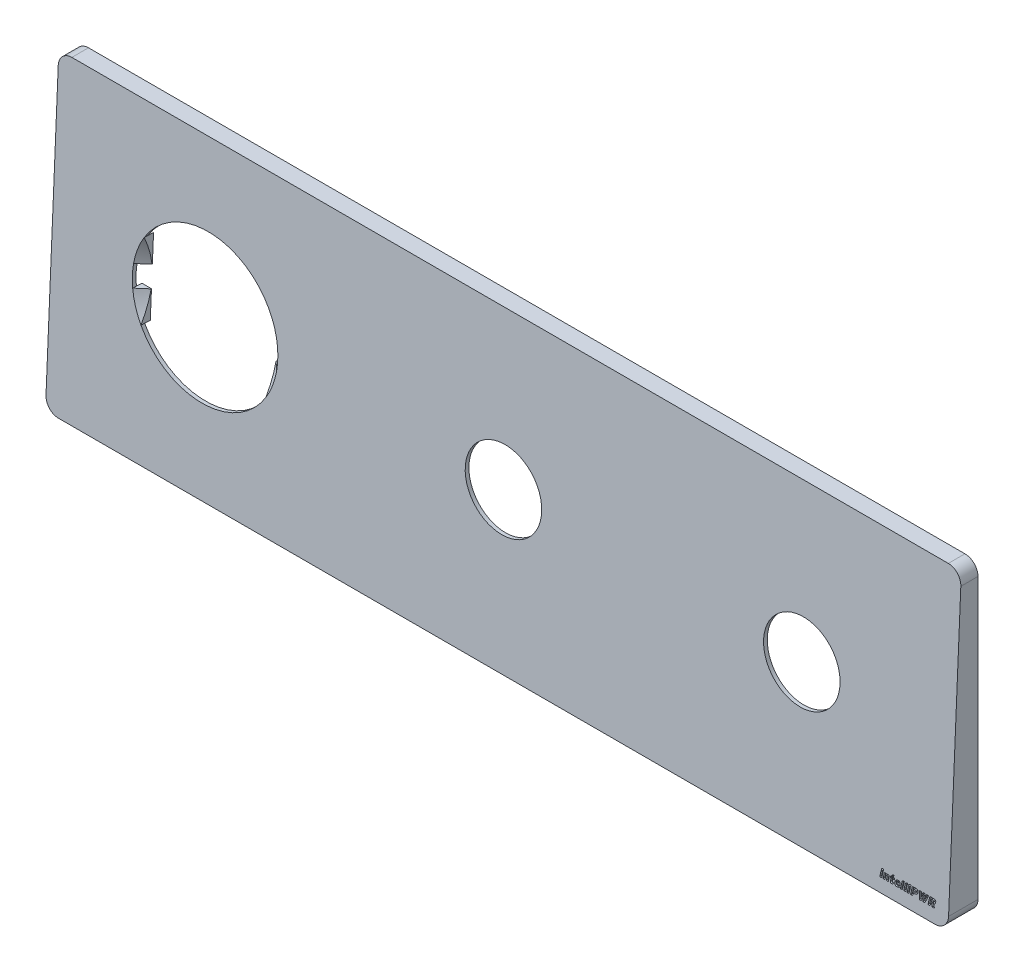
from build123d import *

# Parameters (mm, degrees)
EXTRUDE_THIN1_DEPTH         = 8
CUT_EXTRUDE2_DEPTH          = 242
BOSS_EXTRUDE1_DEPTH         = 242
KES_EKSTR_ZYON5_DEPTH       = 10
SKETCH8_R                   = 19.5
CUT_EXTRUDE3_DEPTH          = 82
CUT_EXTRUDE13_DEPTH         = 0.5
Y_KSEKLIK_EKSTR_ZYON1_DEPTH = 2.5
Y_KSEKLIK_EKSTR_ZYON4_REACH = 10.045
IZIM7_R                     = 5
KES_EKSTR_ZYON2_DEPTH       = 3
IZIM18_W                    = 228
IZIM18_H                    = 68
KES_EKSTR_ZYON8_DEPTH       = 1.5
IZIM19_R                    = 1.55
KES_EKSTR_ZYON10_DEPTH      = 2
IZIM20_R                    = 10.25
KES_EKSTR_ZYON11_DEPTH      = 2


with BuildPart() as part:
    # Sketch1 → Extrude-Thin1 (new body)
    with BuildSketch(Plane.XY):
        with BuildLine():
            Line((-37.5, 41), (197.5, 41))
            ThreePointArc((197.5, 41), (199.974873734, 39.974873734), (201, 37.5))
            Line((201, 37.5), (201, -37.5))
            ThreePointArc((201, -37.5), (199.974873734, -39.974873734), (197.5, -41))
            Line((197.5, -41), (-37.5, -41))
            ThreePointArc((-37.5, -41), (-39.974873734, -39.974873734), (-41, -37.5))
            Line((-41, -37.5), (-41, 37.5))
            ThreePointArc((-41, 37.5), (-39.974873734, 39.974873734), (-37.5, 41))
        make_face()
        with BuildLine():
            Line((-37.5, 40), (197.5, 40))
            ThreePointArc((197.5, 40), (199.267766953, 39.267766953), (200, 37.5))
            Line((200, 37.5), (200, -37.5))
            ThreePointArc((200, -37.5), (199.267766953, -39.267766953), (197.5, -40))
            Line((197.5, -40), (-37.5, -40))
            ThreePointArc((-37.5, -40), (-39.267766953, -39.267766953), (-40, -37.5))
            Line((-40, -37.5), (-40, 37.5))
            ThreePointArc((-40, 37.5), (-39.267766953, 39.267766953), (-37.5, 40))
        make_face(mode=Mode.SUBTRACT)
    extrude(amount=EXTRUDE_THIN1_DEPTH)

    # Sketch5 → Cut-Extrude2 (cut)
    with BuildSketch(Plane(origin=(201, 0, 0), x_dir=(0, 0, -1), z_dir=(1, 0, 0))):
        Polygon((-3.45625, 41), (-8, 41), (-8, -41), (-7.04375, -41), align=None)
    extrude(amount=-CUT_EXTRUDE2_DEPTH, mode=Mode.SUBTRACT)

    # Sketch6 → Boss-Extrude1 (add)
    with BuildSketch(Plane(origin=(201, 0, 0), x_dir=(0, 0, -1), z_dir=(1, 0, 0))):
        Polygon((-7.04375, -41), (-3.45625, 41), (-4.457206574, 41), (-8.044706574, -41), align=None)
    extrude(amount=-BOSS_EXTRUDE1_DEPTH)

    # Sketch7 → Kes-Ekstrüzyon5 (cut)
    with BuildSketch(Plane(origin=(0, 0, 0), x_dir=(-1, 0, 0), z_dir=(0, 0, -1))):
        with BuildLine():
            Line((-201, 37.5), (-201, 41))
            Line((-201, 41), (-197.5, 41))
            ThreePointArc((-197.5, 41), (-199.974873734, 39.974873734), (-201, 37.5))
        make_face()
        with BuildLine():
            Line((41, 41), (37.5, 41))
            ThreePointArc((37.5, 41), (39.974873734, 39.974873734), (41, 37.5))
            Line((41, 37.5), (41, 41))
        make_face()
        with BuildLine():
            Line((41, -37.5), (41, -41))
            Line((41, -41), (37.5, -41))
            ThreePointArc((37.5, -41), (39.974873734, -39.974873734), (41, -37.5))
        make_face()
        with BuildLine():
            Line((-201, -41), (-197.5, -41))
            ThreePointArc((-197.5, -41), (-199.974873734, -39.974873734), (-201, -37.5))
            Line((-201, -37.5), (-201, -41))
        make_face()
    extrude(amount=-KES_EKSTR_ZYON5_DEPTH, mode=Mode.SUBTRACT)

    # Sketch8 → Cut-Extrude3 (cut)
    with BuildSketch(Plane(origin=(0, 0.272956894, 6.23901471), x_dir=(1, 0, 0), z_dir=(0, 0.04370819, 0.99904434))):
        Circle(SKETCH8_R)
    extrude(amount=-CUT_EXTRUDE3_DEPTH, mode=Mode.SUBTRACT)

    # Sketch9 → Cut-Extrude13 (cut)
    with BuildSketch(Plane(origin=(0, 0.272956894, 6.23901471), x_dir=(1, 0, 0), z_dir=(0, 0.04370819, 0.99904434))):
        Polygon((182.531822821, -37.81243752), (182.856252467, -36.277424239), (183.382446053, -36.277424239), (183.058016406, -37.81243752), align=None)
        with BuildLine():
            Line((184.290595271, -37.81243752), (184.474593832, -36.930090398))
            add(Edge.make_bspline(
                [(184.474593832, -36.930090398), (184.478802242, -36.907040936), (184.485699122, -36.874149701), (184.489204408, -36.831864189), (184.489786804, -36.805005948), (184.488227016, -36.781187681), (184.484505468, -36.760299642), (184.478846794, -36.742301837), (184.467897911, -36.722954035), (184.449713773, -36.703469949), (184.410825862, -36.680379912), (184.375667943, -36.67553935), (184.351928125, -36.675453309)],
                knots=[0, 0, 0, 0, 0.206248224, 0.294567954, 0.37266766, 0.442257727, 0.504010297, 0.558886264, 0.607164005, 0.698384721, 0.78958017, 1, 1, 1, 1], degree=3))
            add(Edge.make_bspline(
                [(184.351928125, -36.675453309), (184.325473284, -36.67484558), (184.286525614, -36.681302878), (184.239553647, -36.702765608), (184.213865624, -36.721381884), (184.194964801, -36.739763636), (184.182562108, -36.757605017), (184.170154917, -36.777822133), (184.158964314, -36.801354271), (184.147757062, -36.827440773), (184.134571616, -36.86862437), (184.125790697, -36.901180323), (184.120978207, -36.924168606)],
                knots=[0, 0, 0, 0, 0.211446307, 0.310998659, 0.41131055, 0.464021143, 0.521401463, 0.584741643, 0.653943237, 0.72987757, 0.812025534, 1, 1, 1, 1], degree=3))
            Line((184.120978207, -36.924168606), (183.936556661, -37.81243752))
            Line((183.936556661, -37.81243752), (183.410363076, -37.81243752))
            Line((183.410363076, -37.81243752), (183.734792722, -36.26938752))
            Line((183.734792722, -36.26938752), (184.260986308, -36.26938752))
            Line((184.260986308, -36.26938752), (184.240683018, -36.373441879))
            add(Edge.make_bspline(
                [(184.240683018, -36.373441879), (184.297987543, -36.33807022), (184.373085655, -36.296555731), (184.471607475, -36.262409613), (184.549233248, -36.246533575), (184.610636762, -36.242418025), (184.653093586, -36.242316467)],
                knots=[0, 0, 0, 0, 0.46054381, 0.581347921, 0.710250487, 1, 1, 1, 1], degree=3))
            add(Edge.make_bspline(
                [(184.653093586, -36.242316467), (184.692136802, -36.242431818), (184.748815156, -36.246238609), (184.8195399, -36.26391656), (184.865428391, -36.281339933), (184.906090192, -36.304634337), (184.94136314, -36.333047361), (184.971485528, -36.366619173), (184.996169238, -36.405109022), (185.015420474, -36.448469614), (185.030965908, -36.495857326), (185.040105685, -36.548112348), (185.04586972, -36.604390706), (185.045678226, -36.66521683), (185.04090151, -36.755484326), (185.027642856, -36.824675469), (185.018552796, -36.872141426)],
                knots=[0, 0, 0, 0, 0.133987507, 0.193275728, 0.24925757, 0.301629359, 0.35316106, 0.403792674, 0.455518759, 0.509134706, 0.565968881, 0.625945932, 0.6905051, 0.759590801, 0.83411591, 1, 1, 1, 1], degree=3))
            Line((185.018552796, -36.872141426), (184.819749753, -37.81243752))
            Line((184.819749753, -37.81243752), (184.290595271, -37.81243752))
        make_face()
        with BuildLine():
            Line((185.394586637, -37.347153803), (185.534594737, -36.675453309))
            Line((185.534594737, -36.675453309), (185.300683923, -36.675453309))
            Line((185.300683923, -36.675453309), (185.388664844, -36.26938752))
            Line((185.388664844, -36.26938752), (185.622575658, -36.26938752))
            Line((185.622575658, -36.26938752), (185.704211801, -35.881087109))
            Line((185.704211801, -35.881087109), (186.259591365, -35.673824362))
            Line((186.259591365, -35.673824362), (186.133964762, -36.26938752))
            Line((186.133964762, -36.26938752), (186.467277097, -36.26938752))
            Line((186.467277097, -36.26938752), (186.379719161, -36.675453309))
            Line((186.379719161, -36.675453309), (186.046406826, -36.675453309))
            Line((186.046406826, -36.675453309), (185.929239926, -37.238869592))
            add(Edge.make_bspline(
                [(185.929239926, -37.238869592), (185.923631424, -37.263216042), (185.918218034, -37.297200918), (185.92312076, -37.33870405), (185.933824276, -37.360093), (185.95091673, -37.374576816), (185.981808804, -37.389433205), (186.009637148, -37.390972473), (186.028641447, -37.391567249)],
                knots=[0, 0, 0, 0, 0.332431059, 0.451864296, 0.549008946, 0.641835514, 0.743993136, 1, 1, 1, 1], degree=3))
            add(Edge.make_bspline(
                [(186.028641447, -37.391567249), (186.064780722, -37.392002115), (186.110181113, -37.38175387), (186.162442535, -37.359627978), (186.203981464, -37.340089416), (186.235299865, -37.32233029), (186.257053454, -37.309931106)],
                knots=[0, 0, 0, 0, 0.43902333, 0.560347006, 0.693743593, 1, 1, 1, 1], degree=3))
            Line((186.257053454, -37.309931106), (186.092935197, -37.757449444))
            add(Edge.make_bspline(
                [(186.092935197, -37.757449444), (186.033275974, -37.783688944), (185.9542673, -37.808911724), (185.856030319, -37.827809595), (185.785408909, -37.836780083), (185.731643106, -37.839786288), (185.695329112, -37.839508573)],
                knots=[0, 0, 0, 0, 0.477930884, 0.605353718, 0.733676339, 1, 1, 1, 1], degree=3))
            add(Edge.make_bspline(
                [(185.695329112, -37.839508573), (185.663071209, -37.839736582), (185.616436461, -37.836590683), (185.557875684, -37.82439235), (185.519836592, -37.812291359), (185.486172578, -37.796278005), (185.456955472, -37.776434565), (185.431516542, -37.753616181), (185.410851111, -37.726296633), (185.394665646, -37.694759799), (185.38251301, -37.658826153), (185.374110771, -37.618366346), (185.370071442, -37.573117994), (185.370413325, -37.523190221), (185.37572401, -37.446876072), (185.386376133, -37.387870854), (185.394586637, -37.347153803)],
                knots=[0, 0, 0, 0, 0.137072389, 0.197691701, 0.253760369, 0.306270191, 0.355445666, 0.403353528, 0.450794793, 0.500090506, 0.553319674, 0.611470956, 0.675245672, 0.745926336, 0.823383702, 1, 1, 1, 1], degree=3))
        make_face()
        with BuildLine():
            Line((187.91938528, -37.189803309), (187.01927278, -37.189803309))
            add(Edge.make_bspline(
                [(187.01927278, -37.189803309), (187.015898274, -37.226457242), (187.01601409, -37.279183424), (187.03669972, -37.341985199), (187.061308535, -37.376691917), (187.093763275, -37.402446593), (187.147771512, -37.428419222), (187.19477816, -37.432833272), (187.226535526, -37.433442783)],
                knots=[0, 0, 0, 0, 0.296055755, 0.414655706, 0.524028038, 0.631630635, 0.743271398, 1, 1, 1, 1], degree=3))
            add(Edge.make_bspline(
                [(187.226535526, -37.433442783), (187.260304962, -37.433236623), (187.31067195, -37.43030854), (187.376808197, -37.419896308), (187.426276206, -37.409482171), (187.476966935, -37.393776547), (187.552204889, -37.368515828), (187.608599837, -37.34239729), (187.647828783, -37.325158573)],
                knots=[0, 0, 0, 0, 0.230947891, 0.344109465, 0.457558095, 0.576207715, 0.70668566, 1, 1, 1, 1], degree=3))
            Line((187.647828783, -37.325158573), (187.779377179, -37.663123745))
            add(Edge.make_bspline(
                [(187.779377179, -37.663123745), (187.727053342, -37.69106355), (187.647293355, -37.728389628), (187.538548692, -37.768901332), (187.457845603, -37.794776995), (187.375596177, -37.814738758), (187.261882842, -37.834279371), (187.174496056, -37.839220378), (187.115713405, -37.839508573)],
                knots=[0, 0, 0, 0, 0.256454148, 0.380104154, 0.501569382, 0.622663836, 0.745735429, 1, 1, 1, 1], degree=3))
            add(Edge.make_bspline(
                [(187.115713405, -37.839508573), (187.062179079, -37.839286621), (186.984150161, -37.83327018), (186.88635986, -37.808329984), (186.821962158, -37.782879161), (186.764092487, -37.750669591), (186.712897628, -37.712208672), (186.667893943, -37.668395916), (186.62986787, -37.618343197), (186.599121942, -37.56243437), (186.574364264, -37.501573328), (186.556779358, -37.435320793), (186.545435886, -37.364186815), (186.541005333, -37.288550103), (186.544084404, -37.180061075), (186.556760714, -37.097618609), (186.568793544, -37.042181476)],
                knots=[0, 0, 0, 0, 0.139838784, 0.202933442, 0.262718436, 0.320042211, 0.375233846, 0.429352927, 0.483441981, 0.53862135, 0.595400523, 0.654488518, 0.717096367, 0.783082629, 0.851912792, 1, 1, 1, 1], degree=3))
            add(Edge.make_bspline(
                [(186.568793544, -37.042181476), (186.583085354, -36.979206373), (186.60848624, -36.887640456), (186.655114524, -36.772897044), (186.694694701, -36.695308707), (186.738238344, -36.623502999), (186.786046479, -36.557832048), (186.837870332, -36.498114858), (186.893872235, -36.444840081), (186.953078454, -36.39729059), (187.015434303, -36.35616866), (187.080683136, -36.32115439), (187.14867641, -36.29247145), (187.219054765, -36.270059906), (187.315753588, -36.248224211), (187.39033929, -36.242847847), (187.440143051, -36.242316467)],
                knots=[0, 0, 0, 0, 0.150666393, 0.221012111, 0.28851275, 0.353592776, 0.416668091, 0.477731317, 0.537737092, 0.596692125, 0.65460536, 0.711686431, 0.769156404, 0.826456793, 0.883737364, 1, 1, 1, 1], degree=3))
            add(Edge.make_bspline(
                [(187.440143051, -36.242316467), (187.48922651, -36.24267976), (187.561151065, -36.24758194), (187.651468494, -36.270502973), (187.711979381, -36.293016875), (187.766658046, -36.323010534), (187.815967781, -36.359353432), (187.859729134, -36.4023055), (187.897814959, -36.451871329), (187.929209579, -36.508297206), (187.953961332, -36.571393781), (187.97038317, -36.641490792), (187.980634306, -36.717983158), (187.982669075, -36.801137222), (187.975856843, -36.92586239), (187.959950401, -37.021979864), (187.946033347, -37.087863877)],
                knots=[0, 0, 0, 0, 0.12523536, 0.182281535, 0.236835406, 0.289223704, 0.340575345, 0.392377008, 0.444879637, 0.499220359, 0.55630156, 0.616919283, 0.68212815, 0.752543466, 0.82841511, 1, 1, 1, 1], degree=3))
            add(Edge.make_bspline(
                [(187.946033347, -37.087863877), (187.940848511, -37.106752883), (187.933318431, -37.141050311), (187.92588395, -37.175490124), (187.91938528, -37.189803309)],
                knots=[0, 0, 0, 0, 0.556454368, 1, 1, 1, 1], degree=3))
        make_face()
        with BuildLine():
            Line((187.089065337, -36.864950678), (187.527700987, -36.864950678))
            add(Edge.make_bspline(
                [(187.527700987, -36.864950678), (187.529337401, -36.829487736), (187.529026457, -36.77893147), (187.514215784, -36.717849161), (187.500871129, -36.6876486), (187.487156087, -36.667260541), (187.473605439, -36.655183968), (187.4583103, -36.644290122), (187.440041106, -36.635904218), (187.419470388, -36.629193279), (187.387146007, -36.622924997), (187.361546751, -36.621026515), (187.343702426, -36.621311204)],
                knots=[0, 0, 0, 0, 0.296748963, 0.41669466, 0.52130206, 0.570189777, 0.620055625, 0.671541666, 0.72618717, 0.786738208, 0.851474558, 1, 1, 1, 1], degree=3))
            add(Edge.make_bspline(
                [(187.343702426, -36.621311204), (187.315511409, -36.621200824), (187.27322467, -36.62837339), (187.223193569, -36.654754005), (187.18938015, -36.682031228), (187.158746996, -36.716815862), (187.120773112, -36.776433731), (187.10084266, -36.828342644), (187.089065337, -36.864950678)],
                knots=[0, 0, 0, 0, 0.222963425, 0.331063086, 0.443598367, 0.564296996, 0.69558842, 1, 1, 1, 1], degree=3))
        make_face(mode=Mode.SUBTRACT)
        Polygon((188.08138861, -37.81243752), (188.4874544, -35.884893976), (189.057638446, -35.673824362), (188.607582196, -37.81243752), align=None)
        Polygon((188.974733347, -37.81243752), (189.380799137, -35.884893976), (189.950983183, -35.673824362), (189.500926933, -37.81243752), align=None)
        Polygon((189.868078084, -37.81243752), (190.19250773, -36.277424239), (190.718701316, -36.277424239), (190.394271669, -37.81243752), align=None)
        with BuildLine():
            Line((191.772780428, -37.135661204), (191.489380345, -37.135661204))
            Line((191.489380345, -37.135661204), (191.34894926, -37.81243752))
            Line((191.34894926, -37.81243752), (190.790608799, -37.81243752))
            Line((190.790608799, -37.81243752), (191.223322656, -35.75503752))
            Line((191.223322656, -35.75503752), (192.103131867, -35.75503752))
            add(Edge.make_bspline(
                [(192.103131867, -35.75503752), (192.159534536, -35.754461725), (192.241971066, -35.759373362), (192.34812403, -35.774557347), (192.42051447, -35.790648003), (192.487750703, -35.810772195), (192.548378699, -35.837608583), (192.602942888, -35.869231698), (192.650276048, -35.907283046), (192.691096218, -35.950762718), (192.72462258, -36.000691089), (192.750395085, -36.056994678), (192.768534882, -36.119550733), (192.779127087, -36.188477535), (192.781433901, -36.294101393), (192.769834596, -36.376142847), (192.758335937, -36.432236821)],
                knots=[0, 0, 0, 0, 0.14831325, 0.216934671, 0.281917028, 0.343283354, 0.401251238, 0.455965678, 0.508744428, 0.560452414, 0.612307896, 0.666251039, 0.722712036, 0.783153078, 0.849210812, 1, 1, 1, 1], degree=3))
            add(Edge.make_bspline(
                [(192.758335937, -36.432236821), (192.745018379, -36.493400096), (192.720669996, -36.582253241), (192.670543899, -36.690589416), (192.628175407, -36.76221581), (192.579864514, -36.826142449), (192.527763822, -36.884522206), (192.469918315, -36.935510004), (192.407912463, -36.980860955), (192.341061715, -37.019087162), (192.270613234, -37.052413334), (192.195941581, -37.079438209), (192.117438362, -37.100302612), (192.035627861, -37.116510214), (191.920519083, -37.130666622), (191.832448592, -37.136469779), (191.772780428, -37.135661204)],
                knots=[0, 0, 0, 0, 0.14135813, 0.206506788, 0.268663819, 0.328624165, 0.386922124, 0.444795496, 0.502155746, 0.559848074, 0.618159034, 0.677698161, 0.738624222, 0.801161417, 0.865596376, 1, 1, 1, 1], degree=3))
        make_face()
        with BuildLine():
            Line((191.992309745, -36.215245415), (191.685222492, -36.215245415))
            Line((191.685222492, -36.215245415), (191.58582097, -36.675453309))
            Line((191.58582097, -36.675453309), (191.884025535, -36.675453309))
            add(Edge.make_bspline(
                [(191.884025535, -36.675453309), (191.925283313, -36.675209328), (191.984662794, -36.670227561), (192.055154824, -36.644667406), (192.096879938, -36.618845247), (192.130162263, -36.584340573), (192.167941671, -36.52744984), (192.183954356, -36.476480956), (192.191112788, -36.44111951)],
                knots=[0, 0, 0, 0, 0.290619666, 0.412091533, 0.523258856, 0.631698278, 0.745850168, 1, 1, 1, 1], degree=3))
            add(Edge.make_bspline(
                [(192.191112788, -36.44111951), (192.198110418, -36.410987258), (192.203090618, -36.36614806), (192.190734347, -36.310322247), (192.175987355, -36.281723428), (192.160016208, -36.261866207), (192.144631485, -36.249338003), (192.126367347, -36.238587545), (192.105357328, -36.229711955), (192.081040299, -36.223694155), (192.043444894, -36.216386171), (192.013189918, -36.215204357), (191.992309745, -36.215245415)],
                knots=[0, 0, 0, 0, 0.254137898, 0.360692933, 0.46331412, 0.514097368, 0.56812747, 0.624481852, 0.687008785, 0.753851467, 0.828927712, 1, 1, 1, 1], degree=3))
        make_face(mode=Mode.SUBTRACT)
        with BuildLine():
            Line((194.659231414, -37.81243752), (194.129230962, -37.81243752))
            Line((194.129230962, -37.81243752), (194.129230962, -37.365765152))
            add(Edge.make_bspline(
                [(194.129230962, -37.365765152), (194.126900951, -37.283994804), (194.128252893, -37.160536588), (194.13547643, -36.997616177), (194.140789961, -36.879311843), (194.146666584, -36.769053746), (194.151864415, -36.683348569), (194.155460175, -36.621114495), (194.160496198, -36.570625063), (194.164210151, -36.535200839), (194.167722615, -36.513449979)],
                knots=[0, 0, 0, 0, 0.287418182, 0.433706581, 0.573086252, 0.703582808, 0.821711634, 0.874841658, 0.922616611, 1, 1, 1, 1], degree=3))
            add(Edge.make_bspline(
                [(194.167722615, -36.513449979), (194.161496588, -36.535520096), (194.149299246, -36.570573469), (194.134017602, -36.621303223), (194.118978254, -36.666114788), (194.103325378, -36.714945055), (194.085340593, -36.766621059), (194.066093035, -36.820983598), (194.03725522, -36.897664284), (193.9987844, -36.997892012), (193.933873577, -37.161042447), (193.883548654, -37.284308092), (193.849214762, -37.365765152)],
                knots=[0, 0, 0, 0, 0.075537836, 0.122272145, 0.174582572, 0.231301047, 0.291254257, 0.354891756, 0.421348915, 0.56122885, 0.708689565, 1, 1, 1, 1], degree=3))
            Line((193.849214762, -37.365765152), (193.661832319, -37.81243752))
            Line((193.661832319, -37.81243752), (193.144521423, -37.81243752))
            Line((193.144521423, -37.81243752), (193.089110362, -35.75503752))
            Line((193.089110362, -35.75503752), (193.673675905, -35.75503752))
            Line((193.673675905, -35.75503752), (193.656333512, -36.098924485))
            add(Edge.make_bspline(
                [(193.656333512, -36.098924485), (193.65424701, -36.174983918), (193.648264891, -36.290478133), (193.63833161, -36.445240669), (193.629727747, -36.562669926), (193.621321528, -36.67807013), (193.607761646, -36.820968946), (193.598473633, -36.925344182), (193.591616776, -36.992269222)],
                knots=[0, 0, 0, 0, 0.254778508, 0.38725736, 0.519329184, 0.649081567, 0.774717154, 1, 1, 1, 1], degree=3))
            add(Edge.make_bspline(
                [(193.591616776, -36.992269222), (193.61165122, -36.925090754), (193.64627647, -36.821122294), (193.699313362, -36.68033524), (193.744037038, -36.566523172), (193.79127081, -36.450651757), (193.852019877, -36.294789455), (193.898907874, -36.178549694), (193.930850905, -36.101885382)],
                knots=[0, 0, 0, 0, 0.220629604, 0.344767136, 0.47349051, 0.605507784, 0.738597758, 1, 1, 1, 1], degree=3))
            Line((193.930850905, -36.101885382), (194.074242887, -35.75503752))
            Line((194.074242887, -35.75503752), (194.600436472, -35.75503752))
            Line((194.600436472, -35.75503752), (194.597475576, -36.101885382))
            add(Edge.make_bspline(
                [(194.597475576, -36.101885382), (194.595245322, -36.17885342), (194.593744967, -36.295183632), (194.59170112, -36.450432417), (194.58933481, -36.566770504), (194.585265185, -36.680726113), (194.576970765, -36.822355136), (194.568781216, -36.925808509), (194.562367804, -36.992269222)],
                knots=[0, 0, 0, 0, 0.259139328, 0.391547022, 0.522548461, 0.650759617, 0.775290273, 1, 1, 1, 1], degree=3))
            add(Edge.make_bspline(
                [(194.562367804, -36.992269222), (194.582394712, -36.924994766), (194.615222507, -36.82040396), (194.663469422, -36.677898334), (194.702776993, -36.562353946), (194.74497043, -36.44495472), (194.802596037, -36.290539958), (194.846106719, -36.175456577), (194.872415954, -36.098924485)],
                knots=[0, 0, 0, 0, 0.222643769, 0.347663635, 0.477213716, 0.609762054, 0.743343773, 1, 1, 1, 1], degree=3))
            Line((194.872415954, -36.098924485), (195.001003454, -35.75503752))
            Line((195.001003454, -35.75503752), (195.580070189, -35.75503752))
            Line((195.580070189, -35.75503752), (194.659231414, -37.81243752))
        make_face()
        with BuildLine():
            Line((196.593542722, -37.81243752), (196.406583265, -37.135661204))
            Line((196.406583265, -37.135661204), (196.178594243, -37.135661204))
            Line((196.178594243, -37.135661204), (196.032241365, -37.81243752))
            Line((196.032241365, -37.81243752), (195.473900905, -37.81243752))
            Line((195.473900905, -37.81243752), (195.906614762, -35.75503752))
            Line((195.906614762, -35.75503752), (196.821531743, -35.75503752))
            add(Edge.make_bspline(
                [(196.821531743, -35.75503752), (196.877926873, -35.754483807), (196.960384904, -35.759332471), (197.066505033, -35.774612626), (197.139020737, -35.790466145), (197.205953379, -35.811436437), (197.266900634, -35.837465743), (197.321219528, -35.86927989), (197.368651198, -35.906963709), (197.409975253, -35.949728838), (197.443119472, -35.999356773), (197.469792369, -36.054460359), (197.488179297, -36.116142105), (197.499234619, -36.184069182), (197.502091304, -36.288441986), (197.491138593, -36.369579554), (197.479273725, -36.425046073)],
                knots=[0, 0, 0, 0, 0.149105791, 0.218093904, 0.283423508, 0.345229253, 0.403357541, 0.458364359, 0.511192647, 0.563160888, 0.614984401, 0.668362726, 0.724518171, 0.784604297, 0.849908347, 1, 1, 1, 1], degree=3))
            add(Edge.make_bspline(
                [(197.479273725, -36.425046073), (197.471091951, -36.462370246), (197.457436855, -36.517331944), (197.43109931, -36.586817422), (197.410288931, -36.63589911), (197.386568462, -36.682146783), (197.360046921, -36.725521274), (197.331535273, -36.766605713), (197.289678358, -36.81710195), (197.232396706, -36.874721204), (197.129930057, -36.955845139), (197.043268199, -37.00306597), (196.982266118, -37.027799979)],
                knots=[0, 0, 0, 0, 0.140674907, 0.207617019, 0.273117689, 0.336661801, 0.398557529, 0.459984484, 0.520402942, 0.639569431, 0.758047993, 1, 1, 1, 1], degree=3))
            Line((196.982266118, -37.027799979), (197.228020518, -37.81243752))
            Line((197.228020518, -37.81243752), (196.593542722, -37.81243752))
        make_face()
        with BuildLine():
            Line((196.710709622, -36.215245415), (196.368514597, -36.215245415))
            Line((196.368514597, -36.215245415), (196.272073972, -36.675453309))
            Line((196.272073972, -36.675453309), (196.605386308, -36.675453309))
            add(Edge.make_bspline(
                [(196.605386308, -36.675453309), (196.646692183, -36.675332321), (196.705978767, -36.670056218), (196.776403605, -36.643820336), (196.817731516, -36.616951584), (196.851342385, -36.58260588), (196.88863205, -36.525830349), (196.904630746, -36.475608567), (196.912050576, -36.440696525)],
                knots=[0, 0, 0, 0, 0.291424493, 0.412585485, 0.525065724, 0.635142904, 0.748168098, 1, 1, 1, 1], degree=3))
            add(Edge.make_bspline(
                [(196.912050576, -36.440696525), (196.917844475, -36.411390256), (196.922675548, -36.366980493), (196.90794214, -36.31244527), (196.893225565, -36.28331352), (196.876706606, -36.263321356), (196.861459444, -36.249962849), (196.842692221, -36.239762671), (196.822035314, -36.229989575), (196.797925906, -36.22366887), (196.760859123, -36.216450838), (196.731169116, -36.215191251), (196.710709622, -36.215245415)],
                knots=[0, 0, 0, 0, 0.248424975, 0.356513751, 0.46136469, 0.51411026, 0.569240084, 0.626959334, 0.689288847, 0.756873603, 0.831295405, 1, 1, 1, 1], degree=3))
        make_face(mode=Mode.SUBTRACT)
        with BuildLine():
            add(Edge.make_bspline(
                [(183.50511176, -35.900967413), (183.49691936, -35.939534043), (183.47504383, -35.995133722), (183.425881126, -36.056740916), (183.380038303, -36.094110103), (183.328076843, -36.124265142), (183.249409757, -36.153091049), (183.185884765, -36.161544068), (183.142613446, -36.161103309)],
                knots=[0, 0, 0, 0, 0.243996234, 0.362518467, 0.483923593, 0.607810429, 0.732572499, 1, 1, 1, 1], degree=3))
            add(Edge.make_bspline(
                [(183.142613446, -36.161103309), (183.103364668, -36.161400076), (183.046373744, -36.154280511), (182.979352972, -36.124674591), (182.945948828, -36.099189041), (182.924597095, -36.074893347), (182.910930194, -36.055259817), (182.901500015, -36.033273015), (182.894040832, -36.01010401), (182.890391407, -35.984987846), (182.889303064, -35.948291927), (182.893286288, -35.92001209), (182.897282031, -35.900967413)],
                knots=[0, 0, 0, 0, 0.278361244, 0.398908763, 0.514847654, 0.572097947, 0.627438768, 0.683254165, 0.740686715, 0.799243397, 0.862127538, 1, 1, 1, 1], degree=3))
            add(Edge.make_bspline(
                [(182.897282031, -35.900967413), (182.90463722, -35.864843953), (182.926908821, -35.812948349), (182.975049057, -35.754537867), (183.02082171, -35.717115039), (183.07287559, -35.686103781), (183.14944575, -35.654434845), (183.212194736, -35.647389995), (183.253858553, -35.646753309)],
                knots=[0, 0, 0, 0, 0.233168972, 0.351345779, 0.477078281, 0.606225183, 0.734604908, 1, 1, 1, 1], degree=3))
            add(Edge.make_bspline(
                [(183.253858553, -35.646753309), (183.294043937, -35.647611873), (183.353611721, -35.652601871), (183.421520668, -35.685173743), (183.454901582, -35.711763501), (183.475557012, -35.736857178), (183.489276756, -35.75628574), (183.498634374, -35.777727473), (183.506206896, -35.800008962), (183.51029148, -35.823685041), (183.51182755, -35.85767362), (183.50937443, -35.883664153), (183.50511176, -35.900967413)],
                knots=[0, 0, 0, 0, 0.289932119, 0.415109387, 0.533191086, 0.591068146, 0.646913169, 0.702320899, 0.757398382, 0.814668092, 0.873137526, 1, 1, 1, 1], degree=3))
        make_face()
        with BuildLine():
            add(Edge.make_bspline(
                [(190.841367023, -35.900967413), (190.833174623, -35.939534043), (190.811299094, -35.995133722), (190.762136389, -36.056740916), (190.716293567, -36.094110103), (190.664332107, -36.124265142), (190.58566502, -36.153091049), (190.522140028, -36.161544068), (190.478868709, -36.161103309)],
                knots=[0, 0, 0, 0, 0.243996234, 0.362518467, 0.483923593, 0.607810429, 0.732572499, 1, 1, 1, 1], degree=3))
            add(Edge.make_bspline(
                [(190.478868709, -36.161103309), (190.439619931, -36.161400076), (190.382629007, -36.154280511), (190.315608235, -36.124674591), (190.282204092, -36.099189041), (190.260852358, -36.074893347), (190.247185457, -36.055259817), (190.237755278, -36.033273015), (190.230296095, -36.01010401), (190.226646671, -35.984987846), (190.225558327, -35.948291927), (190.229541551, -35.92001209), (190.233537294, -35.900967413)],
                knots=[0, 0, 0, 0, 0.278361244, 0.398908763, 0.514847654, 0.572097947, 0.627438768, 0.683254165, 0.740686715, 0.799243397, 0.862127538, 1, 1, 1, 1], degree=3))
            add(Edge.make_bspline(
                [(190.233537294, -35.900967413), (190.240892483, -35.864843953), (190.263164084, -35.812948349), (190.31130432, -35.754537867), (190.357076973, -35.717115039), (190.409130853, -35.686103781), (190.485701013, -35.654434845), (190.54845, -35.647389995), (190.590113816, -35.646753309)],
                knots=[0, 0, 0, 0, 0.233168972, 0.351345779, 0.477078281, 0.606225183, 0.734604908, 1, 1, 1, 1], degree=3))
            add(Edge.make_bspline(
                [(190.590113816, -35.646753309), (190.6302992, -35.647611873), (190.689866985, -35.652601871), (190.757775931, -35.685173743), (190.791156845, -35.711763501), (190.811812275, -35.736857178), (190.825532019, -35.75628574), (190.834889637, -35.777727473), (190.842462159, -35.800008962), (190.846546743, -35.823685041), (190.848082813, -35.85767362), (190.845629693, -35.883664153), (190.841367023, -35.900967413)],
                knots=[0, 0, 0, 0, 0.289932119, 0.415109387, 0.533191086, 0.591068146, 0.646913169, 0.702320899, 0.757398382, 0.814668092, 0.873137526, 1, 1, 1, 1], degree=3))
        make_face()
    extrude(amount=-CUT_EXTRUDE13_DEPTH, mode=Mode.SUBTRACT)

    # Çizim2 → Yükseklik-Ekstrüzyon1 (add)
    with BuildSketch(Plane(origin=(0, 0.272956894, 6.23901471), x_dir=(1, 0, 0), z_dir=(0, 0.04370819, 0.99904434))):
        with BuildLine():
            Line((-16.75, 2.8), (-16.75, 9.984362774))
            ThreePointArc((-16.75, 9.984362774), (-18.37843937, 6.517895851), (-19.29792735, 2.8))
            Line((-19.29792735, 2.8), (-16.75, 2.8))
        make_face()
        with BuildLine():
            ThreePointArc((-19.29792735, -2.8), (-18.37843937, -6.517895851), (-16.75, -9.984362774))
            Line((-16.75, -9.984362774), (-16.75, -2.8))
            Line((-16.75, -2.8), (-19.29792735, -2.8))
        make_face()
        with BuildLine():
            Line((16.75, 2.8), (19.29792735, 2.8))
            ThreePointArc((19.29792735, 2.8), (18.37843937, 6.517895851), (16.75, 9.984362774))
            Line((16.75, 9.984362774), (16.75, 2.8))
        make_face()
        with BuildLine():
            ThreePointArc((16.75, -9.984362774), (18.37843937, -6.517895851), (19.29792735, -2.8))
            Line((19.29792735, -2.8), (16.75, -2.8))
            Line((16.75, -2.8), (16.75, -9.984362774))
        make_face()
    extrude(amount=-Y_KSEKLIK_EKSTR_ZYON1_DEPTH)

    # Çizim4 → Kes-Döndür2 (revolve, cut)
    with BuildSketch(Plane(origin=(0, 0, 0), x_dir=(-1, 0, 0), z_dir=(0, -0.99904434, 0.04370819))):
        Polygon((19.5, -6.244982787), (16.9, -3.744982787), (16.9, -6.244982787), align=None)
    revolve(axis=Axis((0, -1.000417569, -22.866687299), (0, 0.04370819, 0.99904434)), mode=Mode.SUBTRACT)

    # Çizim7 → Yükseklik-Ekstrüzyon4 (add, up to next)
    with BuildSketch(Plane(origin=(0, 0, 0), x_dir=(-1, 0, 0), z_dir=(0, 0, -1)), mode=Mode.PRIVATE) as y_kseklik_ekstr_zyon4_sk1:
        with Locations((29, -29)):
            Circle(IZIM7_R)
    y_kseklik_ekstr_zyon4_tool1 = extrude(y_kseklik_ekstr_zyon4_sk1.sketch, amount=-Y_KSEKLIK_EKSTR_ZYON4_REACH, mode=Mode.PRIVATE) - part.part
    add(y_kseklik_ekstr_zyon4_tool1.solids().sort_by_distance((-29, -29, 0))[0])
    # Çizim7 → Yükseklik-Ekstrüzyon4 (add, up to next)
    with BuildSketch(Plane(origin=(0, 0, 0), x_dir=(-1, 0, 0), z_dir=(0, 0, -1)), mode=Mode.PRIVATE) as y_kseklik_ekstr_zyon4_sk2:
        with Locations((29, 29)):
            Circle(IZIM7_R)
    y_kseklik_ekstr_zyon4_tool2 = extrude(y_kseklik_ekstr_zyon4_sk2.sketch, amount=-Y_KSEKLIK_EKSTR_ZYON4_REACH, mode=Mode.PRIVATE) - part.part
    add(y_kseklik_ekstr_zyon4_tool2.solids().sort_by_distance((-29, 29, 0))[0])
    # Çizim7 → Yükseklik-Ekstrüzyon4 (add, up to next)
    with BuildSketch(Plane(origin=(0, 0, 0), x_dir=(-1, 0, 0), z_dir=(0, 0, -1)), mode=Mode.PRIVATE) as y_kseklik_ekstr_zyon4_sk3:
        with Locations((-29, -29)):
            Circle(IZIM7_R)
    y_kseklik_ekstr_zyon4_tool3 = extrude(y_kseklik_ekstr_zyon4_sk3.sketch, amount=-Y_KSEKLIK_EKSTR_ZYON4_REACH, mode=Mode.PRIVATE) - part.part
    add(y_kseklik_ekstr_zyon4_tool3.solids().sort_by_distance((29, -29, 0))[0])
    # Çizim7 → Yükseklik-Ekstrüzyon4 (add, up to next)
    with BuildSketch(Plane(origin=(0, 0, 0), x_dir=(-1, 0, 0), z_dir=(0, 0, -1)), mode=Mode.PRIVATE) as y_kseklik_ekstr_zyon4_sk4:
        with Locations((-29, 29)):
            Circle(IZIM7_R)
    y_kseklik_ekstr_zyon4_tool4 = extrude(y_kseklik_ekstr_zyon4_sk4.sketch, amount=-Y_KSEKLIK_EKSTR_ZYON4_REACH, mode=Mode.PRIVATE) - part.part
    add(y_kseklik_ekstr_zyon4_tool4.solids().sort_by_distance((29, 29, 0))[0])
    # Çizim7 → Yükseklik-Ekstrüzyon4 (add, up to next)
    with BuildSketch(Plane(origin=(0, 0, 0), x_dir=(-1, 0, 0), z_dir=(0, 0, -1)), mode=Mode.PRIVATE) as y_kseklik_ekstr_zyon4_sk5:
        with Locations((-51, -29)):
            Circle(IZIM7_R)
    y_kseklik_ekstr_zyon4_tool5 = extrude(y_kseklik_ekstr_zyon4_sk5.sketch, amount=-Y_KSEKLIK_EKSTR_ZYON4_REACH, mode=Mode.PRIVATE) - part.part
    add(y_kseklik_ekstr_zyon4_tool5.solids().sort_by_distance((51, -29, 0))[0])
    # Çizim7 → Yükseklik-Ekstrüzyon4 (add, up to next)
    with BuildSketch(Plane(origin=(0, 0, 0), x_dir=(-1, 0, 0), z_dir=(0, 0, -1)), mode=Mode.PRIVATE) as y_kseklik_ekstr_zyon4_sk6:
        with Locations((-109, -29)):
            Circle(IZIM7_R)
    y_kseklik_ekstr_zyon4_tool6 = extrude(y_kseklik_ekstr_zyon4_sk6.sketch, amount=-Y_KSEKLIK_EKSTR_ZYON4_REACH, mode=Mode.PRIVATE) - part.part
    add(y_kseklik_ekstr_zyon4_tool6.solids().sort_by_distance((109, -29, 0))[0])
    # Çizim7 → Yükseklik-Ekstrüzyon4 (add, up to next)
    with BuildSketch(Plane(origin=(0, 0, 0), x_dir=(-1, 0, 0), z_dir=(0, 0, -1)), mode=Mode.PRIVATE) as y_kseklik_ekstr_zyon4_sk7:
        with Locations((-131, -29)):
            Circle(IZIM7_R)
    y_kseklik_ekstr_zyon4_tool7 = extrude(y_kseklik_ekstr_zyon4_sk7.sketch, amount=-Y_KSEKLIK_EKSTR_ZYON4_REACH, mode=Mode.PRIVATE) - part.part
    add(y_kseklik_ekstr_zyon4_tool7.solids().sort_by_distance((131, -29, 0))[0])
    # Çizim7 → Yükseklik-Ekstrüzyon4 (add, up to next)
    with BuildSketch(Plane(origin=(0, 0, 0), x_dir=(-1, 0, 0), z_dir=(0, 0, -1)), mode=Mode.PRIVATE) as y_kseklik_ekstr_zyon4_sk8:
        with Locations((-189, -29)):
            Circle(IZIM7_R)
    y_kseklik_ekstr_zyon4_tool8 = extrude(y_kseklik_ekstr_zyon4_sk8.sketch, amount=-Y_KSEKLIK_EKSTR_ZYON4_REACH, mode=Mode.PRIVATE) - part.part
    add(y_kseklik_ekstr_zyon4_tool8.solids().sort_by_distance((189, -29, 0))[0])
    # Çizim7 → Yükseklik-Ekstrüzyon4 (add, up to next)
    with BuildSketch(Plane(origin=(0, 0, 0), x_dir=(-1, 0, 0), z_dir=(0, 0, -1)), mode=Mode.PRIVATE) as y_kseklik_ekstr_zyon4_sk9:
        with Locations((-51, 29)):
            Circle(IZIM7_R)
    y_kseklik_ekstr_zyon4_tool9 = extrude(y_kseklik_ekstr_zyon4_sk9.sketch, amount=-Y_KSEKLIK_EKSTR_ZYON4_REACH, mode=Mode.PRIVATE) - part.part
    add(y_kseklik_ekstr_zyon4_tool9.solids().sort_by_distance((51, 29, 0))[0])
    # Çizim7 → Yükseklik-Ekstrüzyon4 (add, up to next)
    with BuildSketch(Plane(origin=(0, 0, 0), x_dir=(-1, 0, 0), z_dir=(0, 0, -1)), mode=Mode.PRIVATE) as y_kseklik_ekstr_zyon4_sk10:
        with Locations((-109, 29)):
            Circle(IZIM7_R)
    y_kseklik_ekstr_zyon4_tool10 = extrude(y_kseklik_ekstr_zyon4_sk10.sketch, amount=-Y_KSEKLIK_EKSTR_ZYON4_REACH, mode=Mode.PRIVATE) - part.part
    add(y_kseklik_ekstr_zyon4_tool10.solids().sort_by_distance((109, 29, 0))[0])
    # Çizim7 → Yükseklik-Ekstrüzyon4 (add, up to next)
    with BuildSketch(Plane(origin=(0, 0, 0), x_dir=(-1, 0, 0), z_dir=(0, 0, -1)), mode=Mode.PRIVATE) as y_kseklik_ekstr_zyon4_sk11:
        with Locations((-131, 29)):
            Circle(IZIM7_R)
    y_kseklik_ekstr_zyon4_tool11 = extrude(y_kseklik_ekstr_zyon4_sk11.sketch, amount=-Y_KSEKLIK_EKSTR_ZYON4_REACH, mode=Mode.PRIVATE) - part.part
    add(y_kseklik_ekstr_zyon4_tool11.solids().sort_by_distance((131, 29, 0))[0])
    # Çizim7 → Yükseklik-Ekstrüzyon4 (add, up to next)
    with BuildSketch(Plane(origin=(0, 0, 0), x_dir=(-1, 0, 0), z_dir=(0, 0, -1)), mode=Mode.PRIVATE) as y_kseklik_ekstr_zyon4_sk12:
        with Locations((-189, 29)):
            Circle(IZIM7_R)
    y_kseklik_ekstr_zyon4_tool12 = extrude(y_kseklik_ekstr_zyon4_sk12.sketch, amount=-Y_KSEKLIK_EKSTR_ZYON4_REACH, mode=Mode.PRIVATE) - part.part
    add(y_kseklik_ekstr_zyon4_tool12.solids().sort_by_distance((189, 29, 0))[0])

    # Çizim10 → Kes-Ekstrüzyon2 (cut)
    with BuildSketch(Plane.XZ.offset(41)):
        with BuildLine():
            Line((16.479145422, 4.388233566), (-16.479145422, 4.388233566))
            ThreePointArc((-16.479145422, 4.388233566), (-17.649333458, 4.150598487), (-18.634136343, 3.475340206))
            Line((-18.634136343, 3.475340206), (-22, 0))
            Line((-22, 0), (22, 0))
            Line((22, 0), (18.634136343, 3.475340206))
            ThreePointArc((18.634136343, 3.475340206), (17.649333458, 4.150598487), (16.479145422, 4.388233566))
        make_face()
    extrude(amount=-KES_EKSTR_ZYON2_DEPTH, mode=Mode.SUBTRACT)

    # Çizim18 → Kes-Ekstrüzyon8 (cut)
    with BuildSketch(Plane(origin=(0, 0, 0), x_dir=(-1, 0, 0), z_dir=(0, 0, -1))):
        with Locations((-80, 0)):
            Rectangle(IZIM18_W, IZIM18_H)
    extrude(amount=-KES_EKSTR_ZYON8_DEPTH, mode=Mode.SUBTRACT)

    # Çizim19 → Kes-Ekstrüzyon10 (cut)
    with BuildSketch(Plane(origin=(0, 0, 1.5), x_dir=(-1, 0, 0), z_dir=(0, 0, -1))):
        with Locations((-189, 29)):
            Circle(IZIM19_R)
        with Locations((-131, 29)):
            Circle(IZIM19_R)
        with Locations((-109, 29)):
            Circle(IZIM19_R)
        with Locations((-131, -29)):
            Circle(IZIM19_R)
        with Locations((-109, -29)):
            Circle(IZIM19_R)
        with Locations((-189, -29)):
            Circle(IZIM19_R)
        with Locations((-51, -29)):
            Circle(IZIM19_R)
        with Locations((-29, -29)):
            Circle(IZIM19_R)
        with Locations((29, -29)):
            Circle(IZIM19_R)
        with Locations((-29, 29)):
            Circle(IZIM19_R)
        with Locations((29, 29)):
            Circle(IZIM19_R)
        with Locations((-51, 29)):
            Circle(IZIM19_R)
    extrude(amount=-KES_EKSTR_ZYON10_DEPTH, mode=Mode.SUBTRACT)

    # Çizim20 → Kes-Ekstrüzyon11 (cut)
    with BuildSketch(Plane(origin=(0, 0.272956894, 6.23901471), x_dir=(1, 0, 0), z_dir=(0, 0.04370819, 0.99904434))):
        with Locations((80, 0)):
            Circle(IZIM20_R)
        with Locations((160, 0)):
            Circle(IZIM20_R)
    extrude(amount=-KES_EKSTR_ZYON11_DEPTH, mode=Mode.SUBTRACT)


solid = part.part
